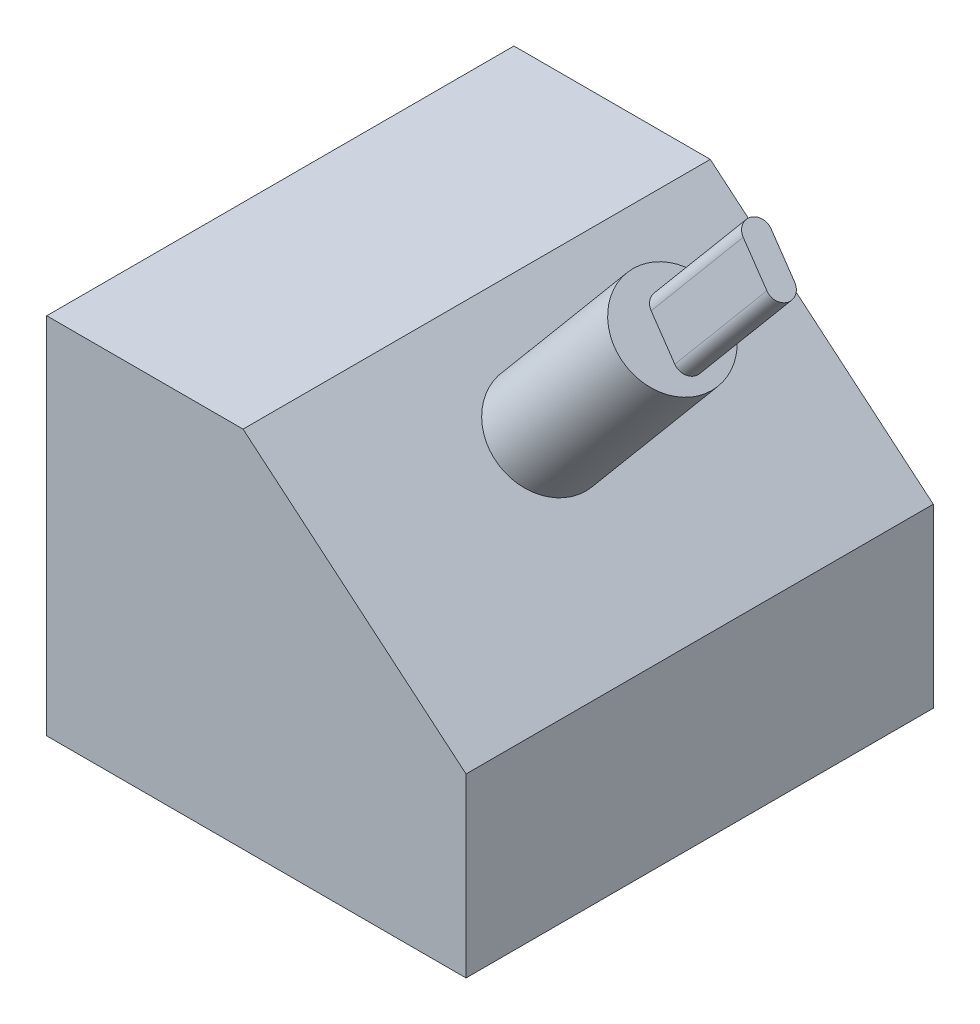
from build123d import *

# Parameters (mm, degrees)
BOSS_EXTRUDE1_DEPTH = 62
SKETCH2_R           = 6.829046467
BOSS_EXTRUDE2_DEPTH = 26
BOSS_EXTRUDE3_DEPTH = 19


with BuildPart() as part:
    # Sketch1 → Boss-Extrude1 (new body)
    with BuildSketch(Plane.XY):
        Polygon((0, 0), (0, 48.281138127), (26.053837569, 48.281138127), (55.644011692, 23.446527703), (55.644011692, 0), align=None)
    extrude(amount=BOSS_EXTRUDE1_DEPTH)

    # Sketch2 → Boss-Extrude2 (add)
    with BuildSketch(Plane(origin=(34.542354114, 41.156847455, 0), x_dir=(0.765974254, -0.642871249, 0), z_dir=(0.642871249, 0.765974254, 0))):
        with Locations((3.286422452, -32.740977781)):
            Circle(SKETCH2_R)
    extrude(amount=BOSS_EXTRUDE2_DEPTH)

    # Sketch3 → Boss-Extrude3 (add)
    with BuildSketch(Plane(origin=(51.257006582, 61.072178055, 0), x_dir=(0.765974254, -0.642871249, 0), z_dir=(0.642871249, 0.765974254, 0))):
        with BuildLine():
            Line((6.231595343, -34.685018308), (0.758276941, -33.629675248))
            ThreePointArc((0.758276941, -33.629675248), (-0.542233107, -31.707846996), (1.379595145, -30.407336949))
            Line((1.379595145, -30.407336949), (6.852913547, -31.462680009))
            ThreePointArc((6.852913547, -31.462680009), (8.153423595, -33.38450826), (6.231595343, -34.685018308))
        make_face()
    extrude(amount=BOSS_EXTRUDE3_DEPTH)


solid = part.part
